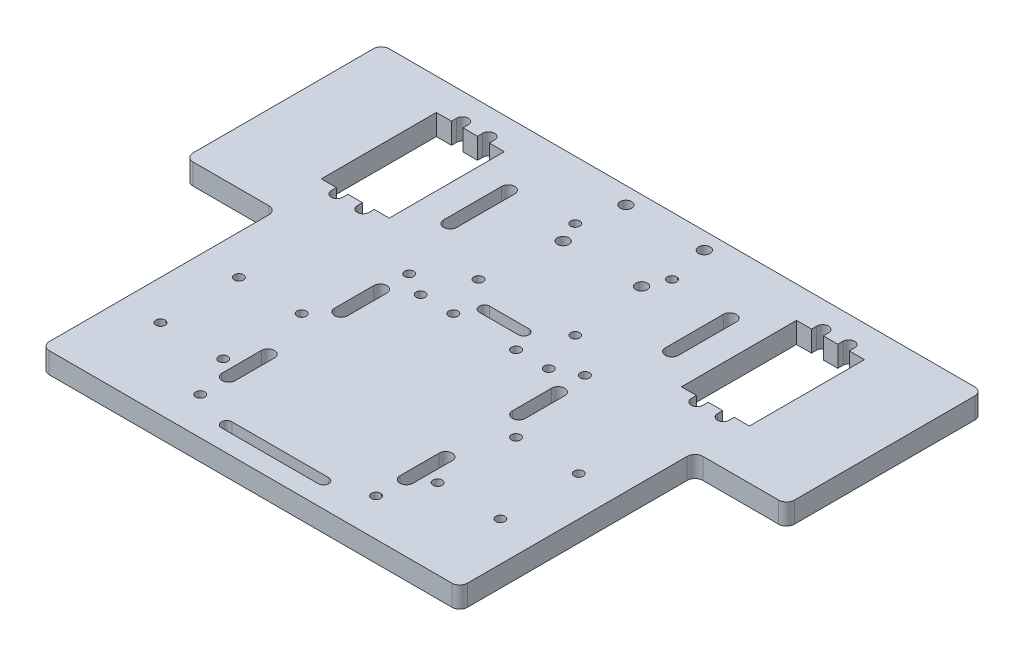
from build123d import *

# Parameters (mm, degrees)
SKETCH_1_W           = 230
SKETCH_1_H           = 200
EXTRUDE_1_DEPTH      = 8
SKETCH_2_R           = 1.75
SKETCH_2_R_2         = 2.2
SKETCH_2_W           = 26
SKETCH_2_H           = 44
CUT_EXTRUDE_2_DEPTH  = 8
CUT_EXTRUDE_3_DEPTH  = 8
CUT_EXTRUDE_5_DEPTH  = 8
CUT_EXTRUDE_6_DEPTH  = 8
CUT_EXTRUDE_7_DEPTH  = 8
SKETCH_2_5_W         = 35
SKETCH_2_5_H         = 90
CUT_EXTRUDE_10_DEPTH = 8
SKETCH_4_W           = 230
SKETCH_4_H           = 35
CUT_EXTRUDE_12_DEPTH = 8
FILLET_1_R           = 3


with BuildPart() as part:
    # 草图1 → 凸台-拉伸1 (new body)
    with BuildSketch(Plane(origin=(0, 0, 0), x_dir=(1, 0, 0), z_dir=(0, 1, 0))):
        with Locations((0, -30.464770869)):
            Rectangle(SKETCH_1_W, SKETCH_1_H)
    extrude(amount=EXTRUDE_1_DEPTH)

    # 草图2 → 切除-拉伸2 (cut)
    with BuildSketch(Plane(origin=(0, 0, 0), x_dir=(1, 0, 0), z_dir=(0, 1, 0))):
        with Locations((-33.6, -36.191664289)):
            Circle(SKETCH_2_R)
        with Locations((33.6, -36.191664289)):
            Circle(SKETCH_2_R)
        with Locations((-33.6, -116.091664289)):
            Circle(SKETCH_2_R)
        with Locations((33.6, -116.091664289)):
            Circle(SKETCH_2_R)
        with Locations((-41, -69.917622991)):
            Circle(SKETCH_2_R)
        with Locations((-41, -99.917622991)):
            Circle(SKETCH_2_R)
        with Locations((-65, -99.917622991)):
            Circle(SKETCH_2_R)
        with Locations((-65, -69.917622991)):
            Circle(SKETCH_2_R)
        with Locations((-24.5, -40.898074934)):
            Circle(SKETCH_2_R)
        with Locations((-12, -40.898074934)):
            Circle(SKETCH_2_R)
        with Locations((-18.5, 12.219522809)):
            Circle(SKETCH_2_R)
        with Locations((18.5, 12.219522809)):
            Circle(SKETCH_2_R)
        with Locations((18.5, -24.780477191)):
            Circle(SKETCH_2_R)
        with Locations((-18.5, -24.780477191)):
            Circle(SKETCH_2_R)
        with Locations((24.5, -40.898074934)):
            Circle(SKETCH_2_R)
        with Locations((12, -40.898074934)):
            Circle(SKETCH_2_R)
        with Locations((41, -69.917622991)):
            Circle(SKETCH_2_R)
        with Locations((41, -99.917622991)):
            Circle(SKETCH_2_R)
        with Locations((65, -99.917622991)):
            Circle(SKETCH_2_R)
        with Locations((65, -69.917622991)):
            Circle(SKETCH_2_R)
        with Locations((-15, 28.10192507)):
            Circle(SKETCH_2_R_2)
        with Locations((-15, 4.10192507)):
            Circle(SKETCH_2_R_2)
        with Locations((15, 28.10192507)):
            Circle(SKETCH_2_R_2)
        with Locations((15, 4.10192507)):
            Circle(SKETCH_2_R_2)
        with Locations((-68.874170888, 0.466727974)):
            Rectangle(SKETCH_2_W, SKETCH_2_H)
        with Locations((68.874170888, 0.466727974)):
            Rectangle(SKETCH_2_W, SKETCH_2_H)
        with BuildLine():
            Line((61.624170888, 24.466727974), (61.624170888, -23.533272026))
            ThreePointArc((61.624170888, -23.533272026), (63.874170888, -25.783272026), (66.124170888, -23.533272026))
            Line((66.124170888, -23.533272026), (66.124170888, 24.466727974))
            ThreePointArc((66.124170888, 24.466727974), (63.874170888, 26.716727974), (61.624170888, 24.466727974))
        make_face()
        with BuildLine():
            Line((-18.5, -119.09368767), (18.5, -119.09368767))
            ThreePointArc((18.5, -119.09368767), (20.5, -121.09368767), (18.5, -123.09368767))
            Line((18.5, -123.09368767), (-18.5, -123.09368767))
            ThreePointArc((-18.5, -123.09368767), (-20.5, -121.09368767), (-18.5, -119.09368767))
        make_face()
        with BuildLine():
            Line((71.674170888, 24.466727974), (71.674170888, -23.533272026))
            ThreePointArc((71.674170888, -23.533272026), (73.874170888, -25.733272026), (76.074170888, -23.533272026))
            Line((76.074170888, -23.533272026), (76.074170888, 24.466727974))
            ThreePointArc((76.074170888, 24.466727974), (73.874170888, 26.666727974), (71.674170888, 24.466727974))
        make_face()
    extrude(amount=CUT_EXTRUDE_2_DEPTH, mode=Mode.SUBTRACT)

    # 草图2<3> → 切除-拉伸3 (cut)
    with BuildSketch(Plane(origin=(0, 0, 0), x_dir=(1, 0, 0), z_dir=(0, 1, 0))):
        with BuildLine():
            Line((-71.674170888, 24.466727974), (-71.674170888, -23.533272026))
            ThreePointArc((-71.674170888, -23.533272026), (-73.874170888, -25.733272026), (-76.074170888, -23.533272026))
            Line((-76.074170888, -23.533272026), (-76.074170888, 24.466727974))
            ThreePointArc((-76.074170888, 24.466727974), (-73.874170888, 26.666727974), (-71.674170888, 24.466727974))
        make_face()
        with BuildLine():
            Line((61.624170888, 24.466727974), (61.624170888, -23.533272026))
            ThreePointArc((61.624170888, -23.533272026), (63.874170888, -25.783272026), (66.124170888, -23.533272026))
            Line((66.124170888, -23.533272026), (66.124170888, 24.466727974))
            ThreePointArc((66.124170888, 24.466727974), (63.874170888, 26.716727974), (61.624170888, 24.466727974))
        make_face()
        with BuildLine():
            Line((-61.624170888, 24.466727974), (-61.624170888, -23.533272026))
            ThreePointArc((-61.624170888, -23.533272026), (-63.874170888, -25.783272026), (-66.124170888, -23.533272026))
            Line((-66.124170888, -23.533272026), (-66.124170888, 24.466727974))
            ThreePointArc((-66.124170888, 24.466727974), (-63.874170888, 26.716727974), (-61.624170888, 24.466727974))
        make_face()
        with BuildLine():
            Line((71.674170888, 24.466727974), (71.674170888, -23.533272026))
            ThreePointArc((71.674170888, -23.533272026), (73.874170888, -25.733272026), (76.074170888, -23.533272026))
            Line((76.074170888, -23.533272026), (76.074170888, 24.466727974))
            ThreePointArc((76.074170888, 24.466727974), (73.874170888, 26.666727974), (71.674170888, 24.466727974))
        make_face()
    extrude(amount=CUT_EXTRUDE_3_DEPTH, mode=Mode.SUBTRACT)

    # 草图3 → 切除-拉伸5 (cut)
    with BuildSketch(Plane(origin=(0, 0, 0), x_dir=(1, 0, 0), z_dir=(0, 1, 0))):
        with BuildLine():
            Line((-39.885757196, 10.474245388), (-39.885757196, -11.716830422))
            ThreePointArc((-39.885757196, -11.716830422), (-42.385757196, -14.216830422), (-44.885757196, -11.716830422))
            Line((-44.885757196, -11.716830422), (-44.885757196, 10.474245388))
            ThreePointArc((-44.885757196, 10.474245388), (-42.385757196, 12.974245388), (-39.885757196, 10.474245388))
        make_face()
        with BuildLine():
            Line((39.885757196, 10.474245388), (39.885757196, -11.716830422))
            ThreePointArc((39.885757196, -11.716830422), (42.385757196, -14.216830422), (44.885757196, -11.716830422))
            Line((44.885757196, -11.716830422), (44.885757196, 10.474245388))
            ThreePointArc((44.885757196, 10.474245388), (42.385757196, 12.974245388), (39.885757196, 10.474245388))
        make_face()
    extrude(amount=CUT_EXTRUDE_5_DEPTH, mode=Mode.SUBTRACT)

    # 草图3<5> → 切除-拉伸6 (cut)
    with BuildSketch(Plane(origin=(0, 0, 0), x_dir=(1, 0, 0), z_dir=(0, 1, 0))):
        with BuildLine():
            Line((-36.5, -104.818717243), (-36.5, -89.818717243))
            ThreePointArc((-36.5, -89.818717243), (-34, -87.318717243), (-31.5, -89.818717243))
            Line((-31.5, -89.818717243), (-31.5, -104.818717243))
            ThreePointArc((-31.5, -104.818717243), (-34, -107.318717243), (-36.5, -104.818717243))
        make_face()
        with BuildLine():
            Line((-31.5, -46.818717243), (-31.5, -61.818717243))
            ThreePointArc((-31.5, -61.818717243), (-34, -64.318717243), (-36.5, -61.818717243))
            Line((-36.5, -61.818717243), (-36.5, -46.818717243))
            ThreePointArc((-36.5, -46.818717243), (-34, -44.318717243), (-31.5, -46.818717243))
        make_face()
        with BuildLine():
            Line((36.5, -104.818717243), (36.5, -89.818717243))
            ThreePointArc((36.5, -89.818717243), (34, -87.318717243), (31.5, -89.818717243))
            Line((31.5, -89.818717243), (31.5, -104.818717243))
            ThreePointArc((31.5, -104.818717243), (34, -107.318717243), (36.5, -104.818717243))
        make_face()
        with BuildLine():
            Line((31.5, -46.818717243), (31.5, -61.818717243))
            ThreePointArc((31.5, -61.818717243), (34, -64.318717243), (36.5, -61.818717243))
            Line((36.5, -61.818717243), (36.5, -46.818717243))
            ThreePointArc((36.5, -46.818717243), (34, -44.318717243), (31.5, -46.818717243))
        make_face()
    extrude(amount=CUT_EXTRUDE_6_DEPTH, mode=Mode.SUBTRACT)

    # 草图3<6> → 切除-拉伸7 (cut)
    with BuildSketch(Plane(origin=(0, 0, 0), x_dir=(1, 0, 0), z_dir=(0, 1, 0))):
        with BuildLine():
            Line((-7.5, -31.500429428), (7.5, -31.500429428))
            ThreePointArc((7.5, -31.500429428), (9.5, -33.500429428), (7.5, -35.500429428))
            Line((7.5, -35.500429428), (-7.5, -35.500429428))
            ThreePointArc((-7.5, -35.500429428), (-9.5, -33.500429428), (-7.5, -31.500429428))
        make_face()
    extrude(amount=CUT_EXTRUDE_7_DEPTH, mode=Mode.SUBTRACT)

    # 草图2<5> → 切除-拉伸10 (cut)
    with BuildSketch(Plane(origin=(0, 0, 0), x_dir=(1, 0, 0), z_dir=(0, 1, 0))):
        with Locations((-97.5, -85.464770869)):
            Rectangle(SKETCH_2_5_W, SKETCH_2_5_H)
        with Locations((97.5, -85.464770869)):
            Rectangle(SKETCH_2_5_W, SKETCH_2_5_H)
    extrude(amount=CUT_EXTRUDE_10_DEPTH, mode=Mode.SUBTRACT)

    # 草图4 → 切除-拉伸12 (cut)
    with BuildSketch(Plane(origin=(0, 0, 0), x_dir=(1, 0, 0), z_dir=(0, 1, 0))):
        with Locations((0, 52.035229131)):
            Rectangle(SKETCH_4_W, SKETCH_4_H)
    extrude(amount=CUT_EXTRUDE_12_DEPTH, mode=Mode.SUBTRACT)

    # 圆角1
    fillet_1_edges = [part.edges().sort_by_distance(p)[0] for p in [
        (115, 4, -34.535229131),
        (115, 4, 40.464770869),
        (80, 4, 40.464770869),
        (80, 4, 130.464770869),
        (-80, 4, 130.464770869),
        (-80, 4, 40.464770869),
        (-115, 4, 40.464770869),
        (-115, 4, -34.535229131),
    ]]
    fillet(fillet_1_edges, radius=FILLET_1_R)


solid = part.part
